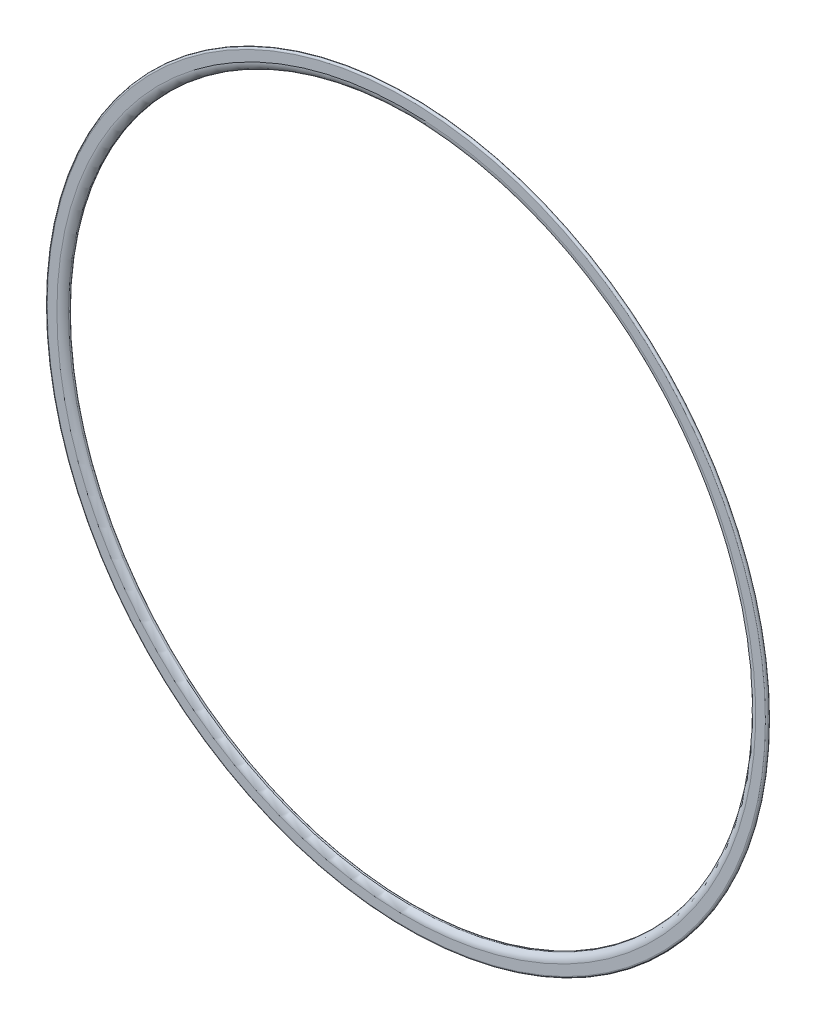
from build123d import *


with BuildPart() as part:
    # Sketch1 → Revolve2 (revolve)
    with BuildSketch(Plane(origin=(0, 0, 0), x_dir=(0, 0, -1), z_dir=(1, 0, 0)), mode=Mode.PRIVATE) as revolve2_sk:
        with BuildLine():
            Line((0.5, 105), (0.5, 102.165063509))
            ThreePointArc((0.5, 102.165063509), (0.700961894, 101.415063509), (1.25, 100.866025404))
            ThreePointArc((1.25, 100.866025404), (1.433012702, 100.183012702), (0.75, 100))
            ThreePointArc((0.75, 100), (-0.165063509, 100.915063509), (-0.5, 102.165063509))
            Line((-0.5, 102.165063509), (-0.5, 105))
            ThreePointArc((-0.5, 105), (0, 105.5), (0.5, 105))
        make_face()
    revolve(revolve2_sk.sketch.rotate(Axis((0, 0, 0), (0, 0, 1)), 90), axis=Axis((0, 0, 0), (0, 0, 1)))  # turned: the seam where the file's is


solid = part.part
